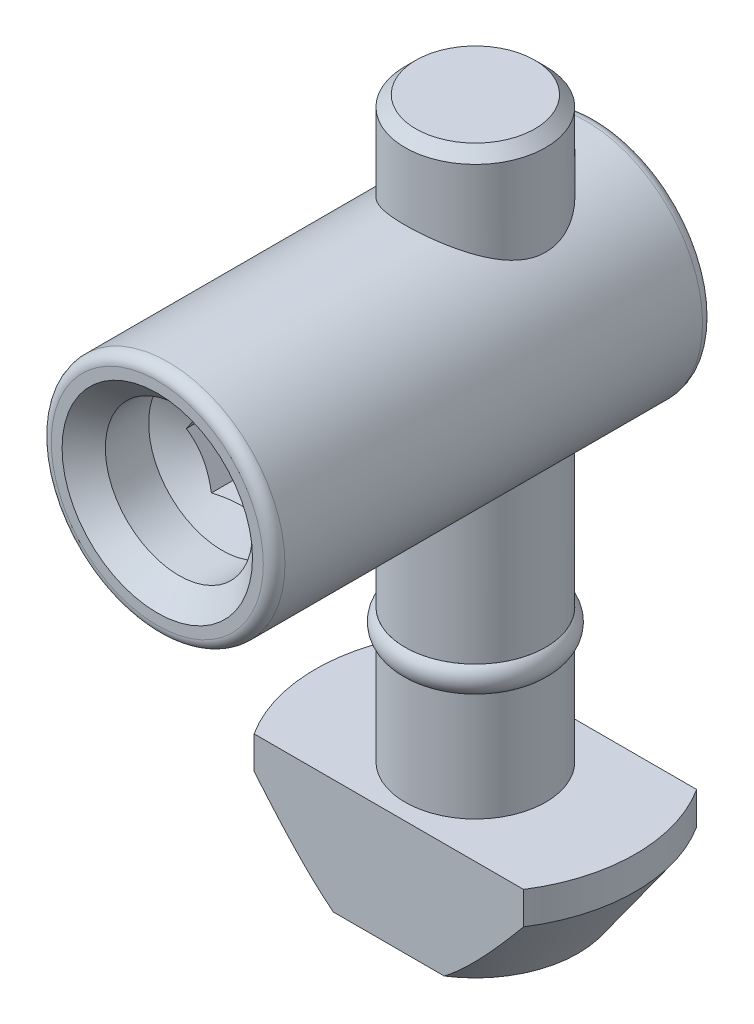
from build123d import *

# Parameters (mm, degrees)
SKETCH_6_OUTSIDE_W          = 24.448
SKETCH_6_OUTSIDE_H          = 24.448
SKETCH_6_OUTSIDE_W_2        = 14.8
SKETCH_6_OUTSIDE_H_2        = 8
CUT_EXTRUDE_1_DEPTH         = 5.3
CHAMFER_1_SIZE              = 0.5
SKETCH_12_R                 = 5.4
EXTRUDE_2_DEPTH             = 14.7
EXTRUDE_2_DEPTH_BACK        = 5.6
HOLE_WIZARD_M81_D           = 6.8
HOLE_WIZARD_M81_DEPTH       = 3
HOLE_WIZARD_M81_CSINK_D     = 8.8
HOLE_WIZARD_M81_CSINK_ANGLE = 90
HOLE_WIZARD_M81_TIP         = 2.042926105
FILLET_1_R                  = 0.5
CUT_EXTRUDE_2_DEPTH         = 6


with BuildPart() as part:
    # Эскиз3 → Повернуть1 (revolve)
    with BuildSketch(Plane.XY, mode=Mode.PRIVATE) as revolve_1_sk:
        Polygon((0, 0), (-3.25, 0), (-3.25, -20.5), (-2.75, -20.5), (-2.75, -21.7), (-3.25, -21.7), (-3.25, -26.7), (-7.4, -26.7), (-7.4, -28.2), (-4.75, -32), (0, -32), align=None)
    revolve(revolve_1_sk.sketch.rotate(Axis((0, 0, 0), (0, 1, 0)), 270), axis=Axis((0, 0, 0), (0, 1, 0)))  # turned: the seam where the file's is

    # Эскиз6 outside → Вырез-Вытянуть1 (cut)
    with BuildSketch(Plane.XZ.offset(32)):
        Rectangle(SKETCH_6_OUTSIDE_W, SKETCH_6_OUTSIDE_H)
        Rectangle(SKETCH_6_OUTSIDE_W_2, SKETCH_6_OUTSIDE_H_2, mode=Mode.SUBTRACT)
    extrude(amount=-CUT_EXTRUDE_1_DEPTH, mode=Mode.SUBTRACT)

    # Фаска1
    chamfer_1_edges = [part.edges().sort_by_distance(p)[0] for p in [
        (0, 0, 3.25),
    ]]
    chamfer(chamfer_1_edges, length=CHAMFER_1_SIZE)

    # Эскиз12 → Бобышка-Вытянуть2 (add, two sides)
    with BuildSketch(Plane.XY) as extrude_2_sk:
        with Locations((0, -9)):
            Circle(SKETCH_12_R)
    extrude(amount=EXTRUDE_2_DEPTH)
    extrude(extrude_2_sk.sketch, amount=-EXTRUDE_2_DEPTH_BACK)

    # Отверстие обработанное метчиком M81
    with Locations(Plane.XY.offset(14.7)):
        with Locations((0, -9)):
            CounterSinkHole(HOLE_WIZARD_M81_D / 2, HOLE_WIZARD_M81_CSINK_D / 2, depth=HOLE_WIZARD_M81_DEPTH, counter_sink_angle=HOLE_WIZARD_M81_CSINK_ANGLE)
            with Locations((0, 0, -(HOLE_WIZARD_M81_DEPTH + HOLE_WIZARD_M81_TIP / 2))):  # 118° drill point
                Cone(0, HOLE_WIZARD_M81_D / 2, HOLE_WIZARD_M81_TIP, mode=Mode.SUBTRACT)

    # Скругление1
    fillet_1_edges = [part.edges().sort_by_distance(p)[0] for p in [
        (-5.4, -9, -5.6),
        (-5.4, -9, 14.7),
    ]]
    fillet(fillet_1_edges, radius=FILLET_1_R)

    # Эскиз15 → Вырез-Вытянуть2 (cut)
    with BuildSketch(Plane.XY.offset(14.7)):
        Polygon((2.309401077, -9), (1.154700538, -7), (-1.154700538, -7), (-2.309401077, -9), (-1.154700538, -11), (1.154700538, -11), align=None)
    extrude(amount=-CUT_EXTRUDE_2_DEPTH, mode=Mode.SUBTRACT)


with BuildPart() as body_2:
    # Эскиз16 → Повернуть2 (revolve)
    with BuildSketch(Plane.XY, mode=Mode.PRIVATE) as revolve_2_sk:
        with BuildLine():
            Line((-2.75, -20.5), (-3.25, -20.5))
            ThreePointArc((-3.25, -20.5), (-3.531024968, -21.1), (-3.25, -21.7))
            Line((-3.25, -21.7), (-2.75, -21.7))
            Line((-2.75, -21.7), (-2.75, -20.5))
        make_face()
    revolve(revolve_2_sk.sketch.rotate(Axis((0, -20.5, 0), (0, -1, 0)), 90), axis=Axis((0, -20.5, 0), (0, -1, 0)))  # turned: the seam where the file's is


solid = Compound([part.part, body_2.part])
